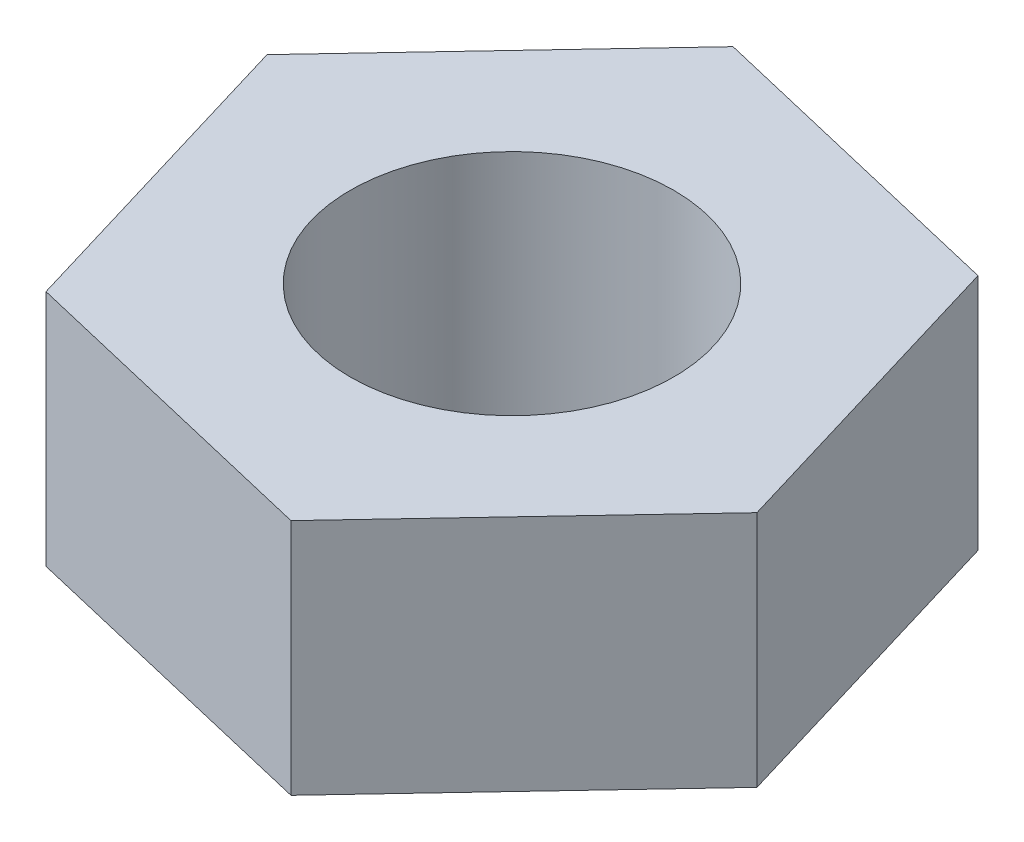
from build123d import *

# Parameters (mm, degrees)
EXTRUDE_1_DEPTH                   = 7.5
HOLE_WIZARD_M12_1_D               = 10.2
HOLE_WIZARD_M12_1_DEPTH           = 29.25
HOLE_WIZARD_M12_1_TIP             = 3.064389157
HOLE_WIZARD_M12_1_ON_FACE_2_D     = 10.2
HOLE_WIZARD_M12_1_ON_FACE_2_DEPTH = 29.25
HOLE_WIZARD_M12_1_ON_FACE_2_TIP   = 3.064389157


with BuildPart() as part:
    # 草图1 → 凸台-拉伸1 (new body)
    with BuildSketch(Plane(origin=(0, 0, 0), x_dir=(1, 0, 0), z_dir=(0, 1, 0))):
        Polygon((2.986206823, -9.954022745), (10.113539979, -2.390880402), (7.127333155, 7.563142343), (-2.986206823, 9.954022745), (-10.113539979, 2.390880402), (-7.127333155, -7.563142343), align=None)
    extrude(amount=EXTRUDE_1_DEPTH)

    # M12 螺纹孔1
    with Locations(Plane(origin=(0, 0, 0), x_dir=(0, 0, -1), z_dir=(0, -1, 0))):
        with Locations((0, 0)):
            Hole(HOLE_WIZARD_M12_1_D / 2, depth=HOLE_WIZARD_M12_1_DEPTH)
            with Locations((0, 0, -(HOLE_WIZARD_M12_1_DEPTH + HOLE_WIZARD_M12_1_TIP / 2))):  # 118° drill point
                Cone(0, HOLE_WIZARD_M12_1_D / 2, HOLE_WIZARD_M12_1_TIP, mode=Mode.SUBTRACT)

    # M12 螺纹孔1 on face 2
    with Locations(Plane.ZX.offset(7.5)):
        with Locations((0, 0)):
            Hole(HOLE_WIZARD_M12_1_ON_FACE_2_D / 2, depth=HOLE_WIZARD_M12_1_ON_FACE_2_DEPTH)
            with Locations((0, 0, -(HOLE_WIZARD_M12_1_ON_FACE_2_DEPTH + HOLE_WIZARD_M12_1_ON_FACE_2_TIP / 2))):  # 118° drill point
                Cone(0, HOLE_WIZARD_M12_1_ON_FACE_2_D / 2, HOLE_WIZARD_M12_1_ON_FACE_2_TIP, mode=Mode.SUBTRACT)


solid = part.part
